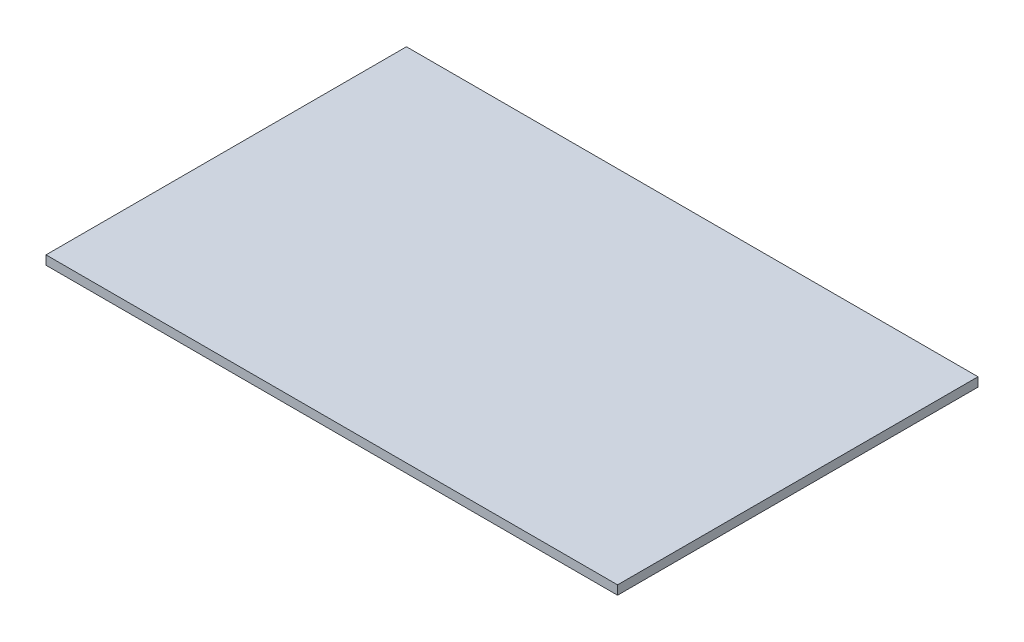
from build123d import *

# Parameters (mm, degrees)
SKETCH1_W           = 85.6
SKETCH1_H           = 53.98
BOSS_EXTRUDE1_DEPTH = 1.35


with BuildPart() as part:
    # Sketch1 → Boss-Extrude1 (new body)
    with BuildSketch(Plane(origin=(0, 0, 0), x_dir=(1, 0, 0), z_dir=(0, 1, 0))):
        Rectangle(SKETCH1_W, SKETCH1_H)
    extrude(amount=BOSS_EXTRUDE1_DEPTH)


solid = part.part
